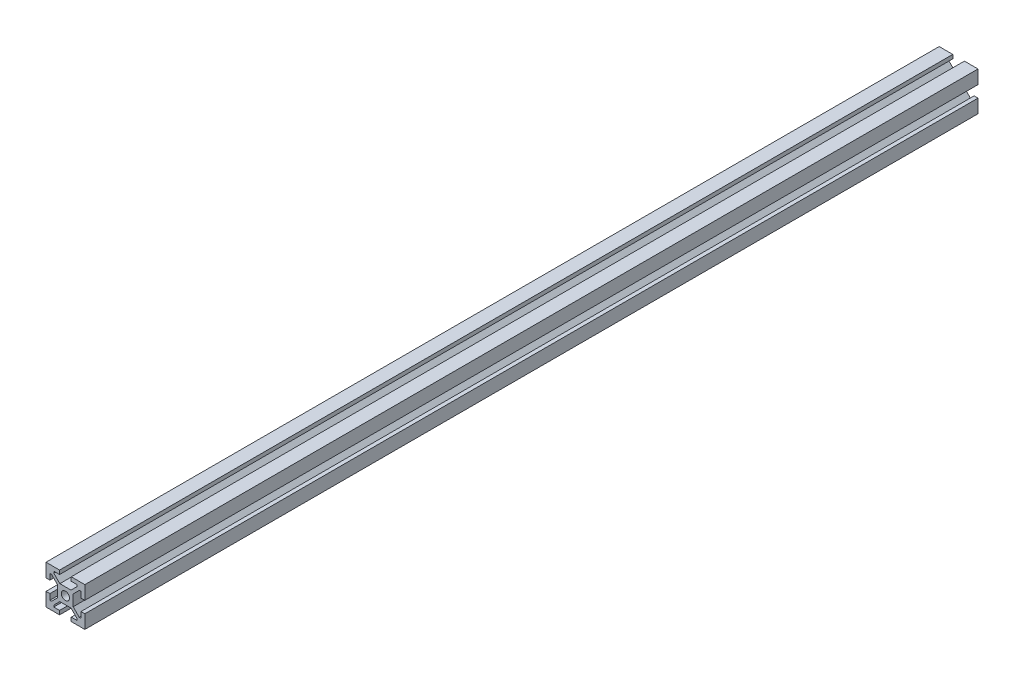
from build123d import *

# Parameters (mm, degrees)
CROQUIS1_R              = 2.1
SALIENTE_EXTRUIR1_DEPTH = 460
CROQUIS2_R              = 2.75
CORTAR_EXTRUIR1_DEPTH   = 21


with BuildPart() as part:
    # Croquis1 → Saliente-Extruir1 (new body)
    with BuildSketch(Plane.XY.offset(460)):
        Polygon((-10, 10), (-10, 3), (-8, 3), (-8, 6), (-7.13137085, 6), (-4, 2.86862915), (-4, -2.86862915), (-7.13137085, -6), (-8, -6), (-8, -3), (-10, -3), (-10, -10), (-3, -10), (-3, -8), (-6, -8), (-6, -7.13137085), (-2.86862915, -4), (2.86862915, -4), (6, -7.13137085), (6, -8), (3, -8), (3, -10), (10, -10), (10, -3), (8, -3), (8, -6), (7.13137085, -6), (4, -2.86862915), (4, 2.86862915), (7.13137085, 6), (8, 6), (8, 3), (10, 3), (10, 10), (3, 10), (3, 8), (6, 8), (6, 7.13137085), (2.86862915, 4), (-2.86862915, 4), (-6, 7.13137085), (-6, 8), (-3, 8), (-3, 10), align=None)
        Circle(CROQUIS1_R, mode=Mode.SUBTRACT)
    extrude(amount=-SALIENTE_EXTRUIR1_DEPTH)

    # Croquis2 → Cortar-Extruir1 (cut, through all)
    with BuildSketch(Plane(origin=(10, 0, 0), x_dir=(0, 0, -1), z_dir=(1, 0, 0))):
        with Locations((-128.4, 0)):
            Circle(CROQUIS2_R)
        with Locations((-331.6, 0)):
            Circle(CROQUIS2_R)
        with Locations((-450, 0)):
            Circle(CROQUIS2_R)
        with Locations((-10, 0)):
            Circle(CROQUIS2_R)
    extrude(amount=-CORTAR_EXTRUIR1_DEPTH, mode=Mode.SUBTRACT)


solid = part.part
